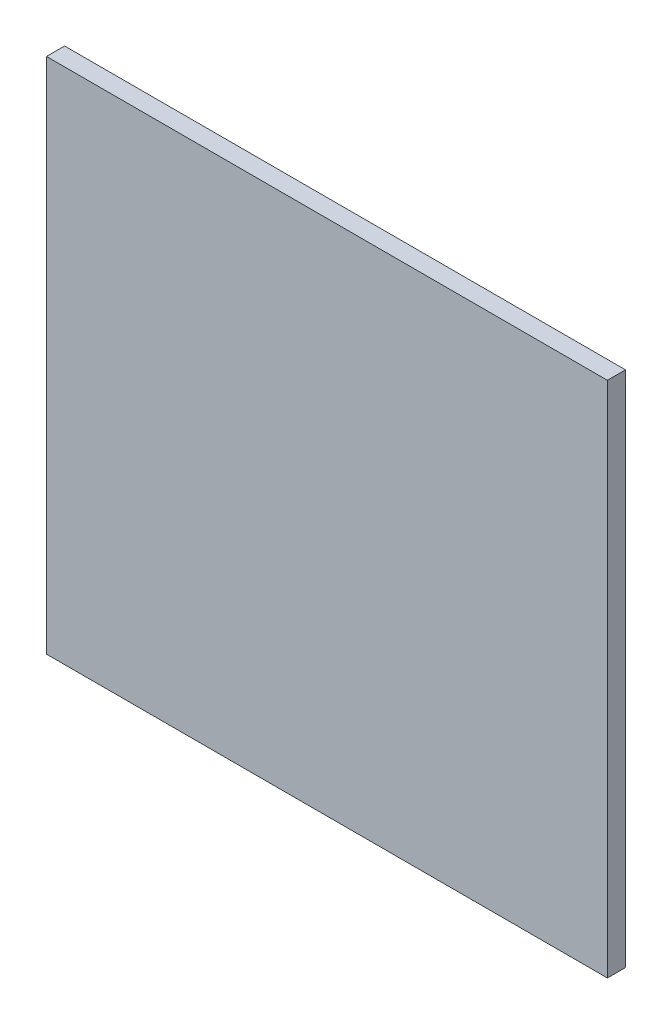
from build123d import *

# Parameters (mm, degrees)
SKETCH1_W           = 558
SKETCH1_H           = 515
BOSS_EXTRUDE1_DEPTH = 18


with BuildPart() as part:
    # Sketch1 → Boss-Extrude1 (new body)
    with BuildSketch(Plane.XY):
        with Locations((-214.65359701, -212.851475477)):
            Rectangle(SKETCH1_W, SKETCH1_H)
    extrude(amount=BOSS_EXTRUDE1_DEPTH)


solid = part.part
